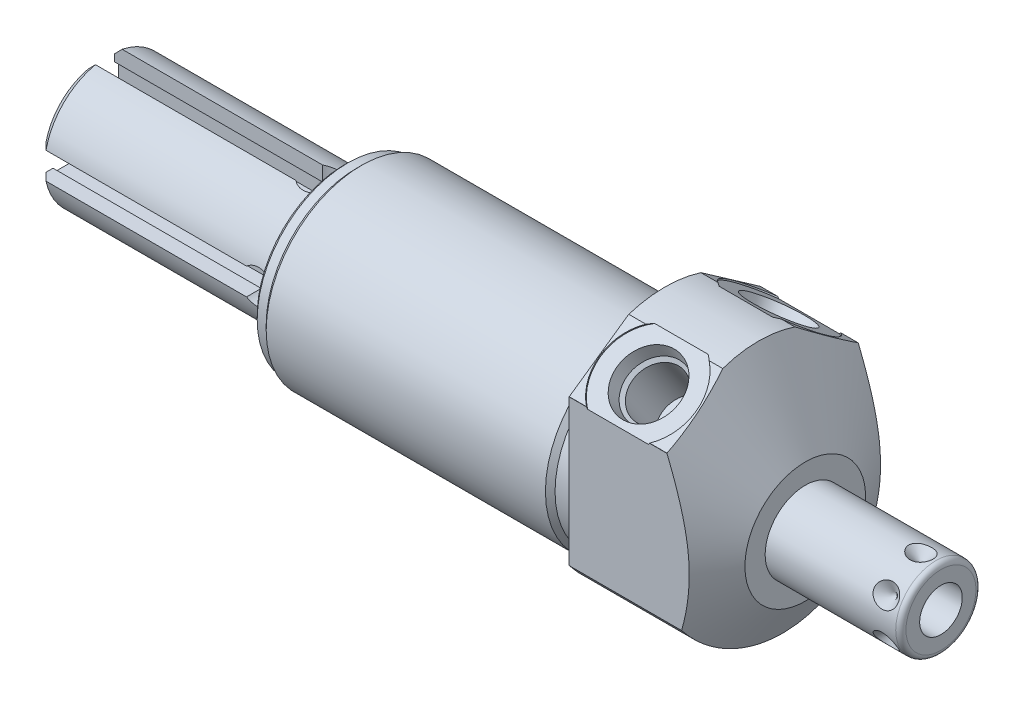
from build123d import *

# Parameters (mm, degrees)
SKETCH1_R           = 23.8125
EXTRUDE1_DEPTH      = 27.7876
EXTRUDE1_DEPTH_BACK = 63.5
CUT_EXTRUDE1_REACH  = 65.5
SKETCH2_R           = 23.8125
SKETCH2_R_2         = 18.8595
CUT_EXTRUDE3_START  = -27.7876
SKETCH4_R           = 28.575
CUT_EXTRUDE3_DEPTH  = 27.7876
SKETCH18_R          = 9.525
CUT_EXTRUDE4_DEPTH  = 0.254
SKETCH19_R          = 9.525
CUT_EXTRUDE5_DEPTH  = 0.254
CHAMFER1_SIZE       = 0.762
CIRPATTERN1_COUNT   = 6
SKETCH20_R          = 12.7
EXTRUDE2_DEPTH      = 48.0314
CHAMFER2_SIZE       = 1.524
SKETCH21_R          = 16.129
SKETCH21_R_2        = 12.7
CUT_EXTRUDE6_DEPTH  = 0.127
SKETCH22_R          = 16.129
SKETCH22_R_2        = 15.875
CUT_EXTRUDE7_DEPTH  = 1.397
CUT_EXTRUDE8_DEPTH  = 43.3832
SKETCH24_R          = 3.429
CUT_EXTRUDE9_DEPTH  = 13.7127001
CIRPATTERN2_COUNT   = 4


with BuildPart() as part:
    # Sketch1 → Extrude1 (new body, two sides)
    with BuildSketch(Plane(origin=(0, 0, 0), x_dir=(0, 0, -1), z_dir=(1, 0, 0))) as extrude1_sk:
        Circle(SKETCH1_R)
    extrude(amount=EXTRUDE1_DEPTH)
    extrude(extrude1_sk.sketch, amount=-EXTRUDE1_DEPTH_BACK)

    # Sketch2 → Cut-Extrude1 (cut, up to next)
    with BuildSketch(Plane(origin=(0, 0, 0), x_dir=(0, 0, -1), z_dir=(1, 0, 0)), mode=Mode.PRIVATE) as cut_extrude1_sk1:
        Circle(SKETCH2_R)
        with Locations((0, -4.191)):
            Circle(SKETCH2_R_2, mode=Mode.SUBTRACT)
    cut_extrude1_tool1 = extrude(cut_extrude1_sk1.sketch, amount=-CUT_EXTRUDE1_REACH, mode=Mode.PRIVATE) & part.part
    add(cut_extrude1_tool1.solids().sort_by_distance((0, 0, 23.138981))[0], mode=Mode.SUBTRACT)

    # Sketch4 → Cut-Extrude3 (cut)
    with BuildSketch(Plane.ZY.offset(CUT_EXTRUDE3_START)):
        Circle(SKETCH4_R)
        with BuildLine():
            Line((18.923, -14.455283714), (18.923, 14.465869871))
            Line((18.923, 14.465869871), (0, 27.715897117))
            Line((0, 27.715897117), (-18.923, 14.465869871))
            Line((-18.923, 14.465869871), (-18.923, -14.455283714))
            ThreePointArc((-18.923, -14.455283714), (0, -23.8125), (18.923, -14.455283714))
        make_face(mode=Mode.SUBTRACT)
    extrude(amount=CUT_EXTRUDE3_DEPTH, mode=Mode.SUBTRACT)

    # Sketch6 → Cut-Revolve2 (revolve, cut)
    with BuildSketch(Plane.XY, mode=Mode.PRIVATE) as cut_revolve2_sk:
        Polygon((4.764025965, 47.625), (27.7876, 7.747), (27.7876, 47.625), align=None)
    revolve(cut_revolve2_sk.sketch.rotate(Axis((3.612847264, -4.191, 0), (1, 0, 0)), 270), axis=Axis((3.612847264, -4.191, 0), (1, 0, 0)), mode=Mode.SUBTRACT)  # turned: the seam where the file's is

    # S2D0002 → Cut-Revolve3 (revolve, cut)
    with BuildSketch(Plane(origin=(9.652, 18.394824642, 12.869035589), x_dir=(0, 0.573576436, -0.819152044), z_dir=(1, 0, 0))):
        Polygon((0, 0), (6.1849, 0), (5.642306865, -2.5527), (4.9784, -3.216606865), (4.9784, -13.462), (0, -13.462), align=None)
    revolve(axis=Axis((9.652, 6.816028581, 4.761475303), (0, 0.819152044, 0.573576436)), mode=Mode.SUBTRACT)

    # Sketch8 → Cut-Revolve4 (revolve, cut)
    with BuildSketch(Plane(origin=(9.652, 18.394824642, -12.869035589), x_dir=(0, -0.573576436, -0.819152044), z_dir=(1, 0, 0))):
        Polygon((0, 0), (6.1849, 0), (5.642306865, -2.5527), (4.9784, -3.216606865), (4.9784, -13.462), (0, -13.462), align=None)
    revolve(axis=Axis((9.652, 6.816028581, -4.761475303), (0, 0.819152044, -0.573576436)), mode=Mode.SUBTRACT)

    # Sketch18 → Cut-Extrude4 (cut)
    with BuildSketch(Plane(origin=(0, 18.59764611, 13.022211999), x_dir=(1, 0, 0), z_dir=(0, 0.819152044, 0.573576436))):
        with Locations((9.652, 0.009141155)):
            Circle(SKETCH18_R)
    extrude(amount=-CUT_EXTRUDE4_DEPTH, mode=Mode.SUBTRACT)

    # Sketch19 → Cut-Extrude5 (cut)
    with BuildSketch(Plane(origin=(0, 18.59764611, -13.022211999), x_dir=(1, 0, 0), z_dir=(0, 0.819152044, -0.573576436))):
        with Locations((9.652, -0.009141155)):
            Circle(SKETCH19_R)
    extrude(amount=-CUT_EXTRUDE5_DEPTH, mode=Mode.SUBTRACT)

    # Sketch10 → Cut-Revolve6 (revolve, cut)
    with BuildSketch(Plane.XY, mode=Mode.PRIVATE) as cut_revolve6_sk:
        Polygon((0, 14.6685), (0, 13.716), (-3.81, 13.716), (-4.7625, 14.6685), align=None)
    revolve(cut_revolve6_sk.sketch.rotate(Axis((-5.000625, -4.191, 0), (1, 0, 0)), 90), axis=Axis((-5.000625, -4.191, 0), (1, 0, 0)), mode=Mode.SUBTRACT)  # turned: the seam where the file's is

    # Sketch12 → Cut-Revolve8 (revolve, cut)
    with BuildSketch(Plane.XY, mode=Mode.PRIVATE) as cut_revolve8_sk:
        Polygon((-63.5, 14.6685), (-63.5, 13.716), (-60.96, 13.716), (-60.0075, 14.6685), align=None)
    revolve(cut_revolve8_sk.sketch.rotate(Axis((-63.674625, -4.191, 0), (1, 0, 0)), 90), axis=Axis((-63.674625, -4.191, 0), (1, 0, 0)), mode=Mode.SUBTRACT)  # turned: the seam where the file's is

    # Chamfer1
    chamfer1_edges = [part.edges().sort_by_distance(p)[0] for p in [
        (-63.5, -4.191, -17.907),
    ]]
    chamfer(chamfer1_edges, length=CHAMFER1_SIZE)

    # Sketch13 → Revolve1 (revolve)
    with BuildSketch(Plane(origin=(0, 0, 0), x_dir=(0, -1, 0), z_dir=(0, 0, 1)), mode=Mode.PRIVATE) as revolve1_sk:
        with BuildLine():
            Line((4.191, 27.7876), (4.191, 54.6354))
            Line((4.191, 54.6354), (11.1125, 54.6354))
            ThreePointArc((11.1125, 54.6354), (11.83092049, 54.33782049), (12.1285, 53.6194))
            Line((12.1285, 53.6194), (12.1285, 27.7876))
            Line((12.1285, 27.7876), (4.191, 27.7876))
        make_face()
    revolve(revolve1_sk.sketch.rotate(Axis((26.44521, -4.191, 0), (1, 0, 0)), 270), axis=Axis((26.44521, -4.191, 0), (1, 0, 0)))  # turned: the seam where the file's is

    # S2D0001 → Cut-Revolve9 (revolve, cut)
    with BuildSketch(Plane(origin=(54.6354, -8.4074, 0), x_dir=(0, -1, 0), z_dir=(0, 0, 1)), mode=Mode.PRIVATE) as cut_revolve9_sk:
        Polygon((0, 0), (0, -15.24), (-4.2164, -17.773468714), (-4.2164, 0), align=None)
    revolve(cut_revolve9_sk.sketch.rotate(Axis((35.97325785, -4.191, 0), (1, 0, 0)), 270), axis=Axis((35.97325785, -4.191, 0), (1, 0, 0)), mode=Mode.SUBTRACT)  # turned: the seam where the file's is

    # Sketch16 → Cut-Revolve10 (revolve, cut)
    with BuildSketch(Plane(origin=(50.673, 3.7465, 0), x_dir=(-1, 0, 0), z_dir=(0, 0, -1)), mode=Mode.PRIVATE) as cut_revolve10_sk:
        Polygon((0, 0), (2.413, 0), (0, -2.413), align=None)
    cut_revolve10 = revolve(cut_revolve10_sk.sketch.rotate(Axis((50.673, -1.324519499, 0), (0, 1, 0)), 90), axis=Axis((50.673, -1.324519499, 0), (0, 1, 0)), mode=Mode.SUBTRACT)  # turned: the seam where the file's is

    # CirPattern1: Cut-Revolve10 ×6 about axis
    cirpattern1_axis = Axis((26.44521, -4.191, 0), (-1, 0, 0))
    for i in range(1, CIRPATTERN1_COUNT):
        add(cut_revolve10.rotate(cirpattern1_axis, i * 360 / CIRPATTERN1_COUNT), mode=Mode.SUBTRACT)

    # Sketch20 → Extrude2 (add)
    with BuildSketch(Plane.ZY.offset(63.5)):
        with Locations(Location((0, -4.191, 0), (0, 0, 180))):  # turned: the seam where the file's is
            Circle(SKETCH20_R)
    extrude(amount=EXTRUDE2_DEPTH)

    # Chamfer2
    chamfer2_edges = [part.edges().sort_by_distance(p)[0] for p in [
        (-111.5314, -4.191, 12.7),
    ]]
    chamfer(chamfer2_edges, length=CHAMFER2_SIZE)

    # Sketch21 → Cut-Extrude6 (cut)
    with BuildSketch(Plane.ZY.offset(63.5)):
        with Locations((0, -4.191)):
            Circle(SKETCH21_R)
        with Locations((0, -4.191)):
            Circle(SKETCH21_R_2, mode=Mode.SUBTRACT)
    extrude(amount=-CUT_EXTRUDE6_DEPTH, mode=Mode.SUBTRACT)

    # Sketch22 → Cut-Extrude7 (cut)
    with BuildSketch(Plane.ZY.offset(63.373)):
        with Locations((0, -4.191)):
            Circle(SKETCH22_R)
        with Locations((0, -4.191)):
            Circle(SKETCH22_R_2, mode=Mode.SUBTRACT)
    extrude(amount=-CUT_EXTRUDE7_DEPTH, mode=Mode.SUBTRACT)

    # Sketch23 → Cut-Extrude8 (cut)
    with BuildSketch(Plane.ZY.offset(111.5314)):
        with BuildLine():
            Line((-12.422236089, -6.8326), (-9.5123, -6.8326))
            Line((-9.5123, -6.8326), (-9.5123, -7.62))
            Line((-9.5123, -7.62), (-6.2103, -7.62))
            Line((-6.2103, -7.62), (-6.2103, -0.762))
            Line((-6.2103, -0.762), (-9.5123, -0.762))
            Line((-9.5123, -0.762), (-9.5123, -1.5494))
            Line((-9.5123, -1.5494), (-12.422236089, -1.5494))
            ThreePointArc((-12.422236089, -1.5494), (-12.7, -4.191), (-12.422236089, -6.8326))
        make_face()
    cut_extrude8 = extrude(amount=-CUT_EXTRUDE8_DEPTH, mode=Mode.SUBTRACT)

    # Sketch24 → Cut-Extrude9 (cut, through all)
    with BuildSketch(Plane(origin=(0, 0, -6.2103), x_dir=(1, 0, 0), z_dir=(0, 0, -1))):
        with Locations((-68.1482, 4.191)):
            Circle(SKETCH24_R)
    cut_extrude9 = extrude(amount=CUT_EXTRUDE9_DEPTH, mode=Mode.SUBTRACT)

    # CirPattern2: Cut-Extrude8, Cut-Extrude9 ×4 about axis
    cirpattern2_axis = Axis((0, -4.191, 0), (1, 0, 0))
    add([cut_extrude8.rotate(cirpattern2_axis, i * 360 / CIRPATTERN2_COUNT) for i in range(1, CIRPATTERN2_COUNT)], mode=Mode.SUBTRACT)
    add([cut_extrude9.rotate(cirpattern2_axis, i * 360 / CIRPATTERN2_COUNT) for i in range(1, CIRPATTERN2_COUNT)], mode=Mode.SUBTRACT)


solid = part.part
